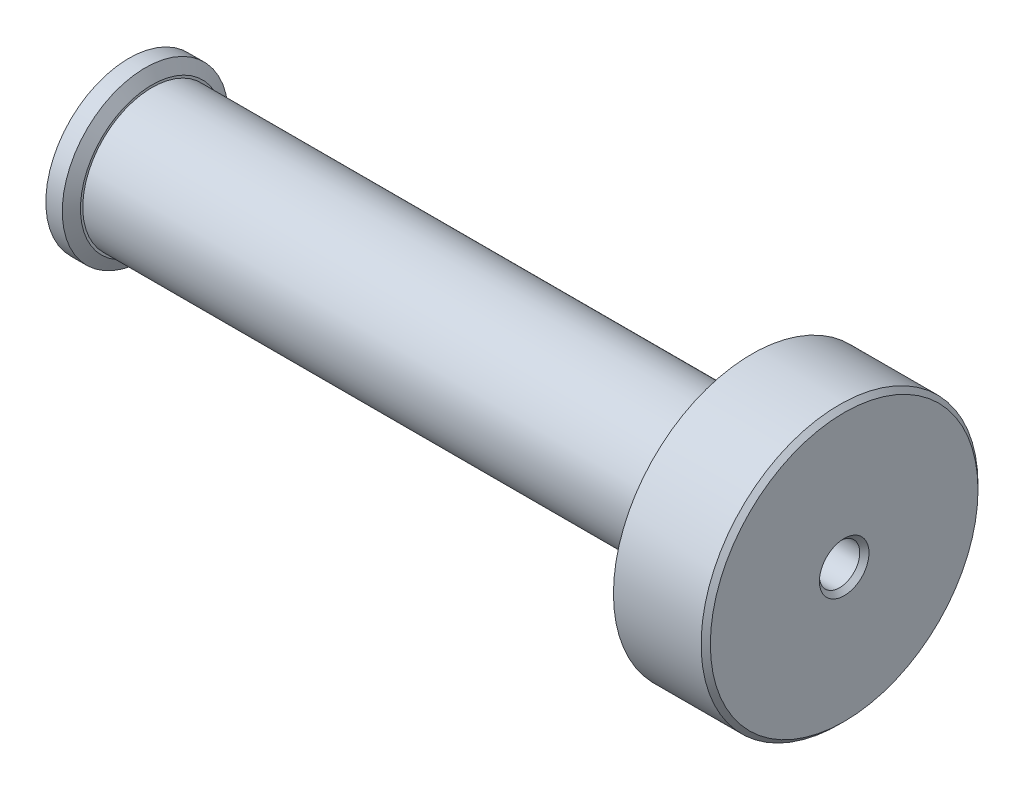
from build123d import *

# Parameters (mm, degrees)
CHAMFER1_SIZE      = 1
CHAMFER1_SIZE2     = 0.577350269
CHAMFER2_SIZE      = 2
CHAMFER2_SIZE2     = 3.464101615
SKETCH4_R          = 4.8
CUT_EXTRUDE1_DEPTH = 53
SKETCH5_R          = 1.75
CUT_EXTRUDE2_DEPTH = 10
CHAMFER3_SIZE      = 0.4


with BuildPart() as part:
    # Sketch3 → Revolve1 (revolve)
    with BuildSketch(Plane(origin=(0, 0, 0), x_dir=(1, 0, 0), z_dir=(0, 1, 0))):
        Polygon((-62, 0), (-62, 7.2), (-60, 7.2), (-60, 6), (-10, 6), (-10, 12), (0, 12), (0, 0), align=None)
    revolve(axis=Axis((0, 0, 0), (-1, 0, 0)))

    # Chamfer1
    chamfer1_edges = [part.edges().sort_by_distance(p)[0] for p in [
        (-60, 0, 7.2),
    ]]
    chamfer1_side = [part.faces().sort_by_distance(p)[0] for p in [
        (-60, 0, 6.996353247),
    ]]
    chamfer(chamfer1_edges, length=CHAMFER1_SIZE, length2=CHAMFER1_SIZE2, reference=chamfer1_side[0])

    # Chamfer2
    chamfer2_edges = [part.edges().sort_by_distance(p)[0] for p in [
        (-10, 0, 12),
    ]]
    chamfer2_side = [part.faces().sort_by_distance(p)[0] for p in [
        (-5, 0, 12),
    ]]
    chamfer(chamfer2_edges, length=CHAMFER2_SIZE, length2=CHAMFER2_SIZE2, reference=chamfer2_side[0])

    # Sketch4 → Cut-Extrude1 (cut)
    with BuildSketch(Plane.ZY.offset(62)):
        Circle(SKETCH4_R)
    extrude(amount=-CUT_EXTRUDE1_DEPTH, mode=Mode.SUBTRACT)

    # Sketch5 → Cut-Extrude2 (cut, through all)
    with BuildSketch(Plane.ZY.offset(9)):
        Circle(SKETCH5_R)
    extrude(amount=-CUT_EXTRUDE2_DEPTH, mode=Mode.SUBTRACT)

    # Chamfer3
    chamfer3_edges = [part.edges().sort_by_distance(p)[0] for p in [
        (0, 0, -1.75),
        (0, 0, 12),
    ]]
    chamfer(chamfer3_edges, length=CHAMFER3_SIZE)


solid = part.part
